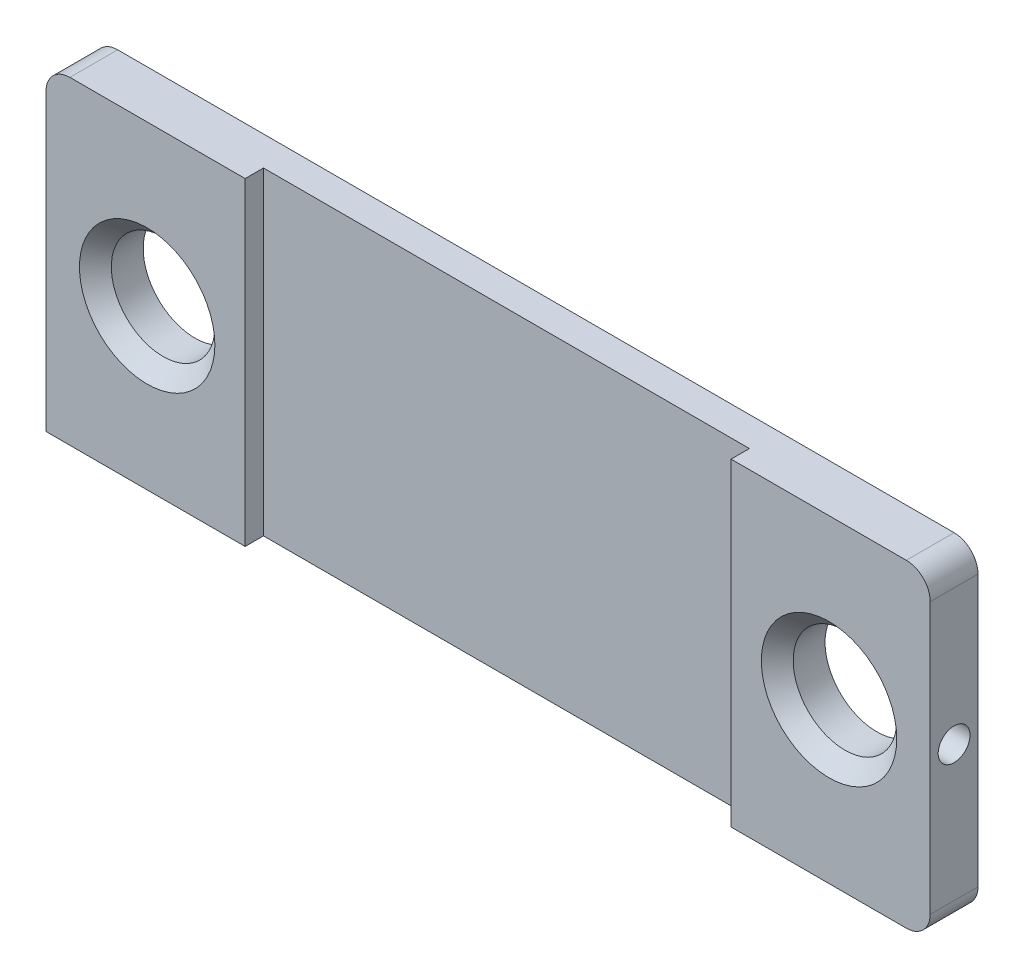
from build123d import *

# Parameters (mm, degrees)
ESQUISSE1_W               = 111
ESQUISSE1_H               = 40
ESQUISSE1_R               = 6.5
EXTRUSION1_DEPTH          = 3
CONG_1_R                  = 3
CHANFREIN1_SIZE           = 2
ESQUISSE2_W               = 61
ESQUISSE2_H               = 40
ENL_V_MAT_EXTRU_1_DEPTH   = 2.3
TROU_TARAUD_M3X0_51_D     = 2.5
TROU_TARAUD_M3X0_51_DEPTH = 7.5
TROU_TARAUD_M3X0_51_TIP   = 0.751075774


with BuildPart() as part:
    # Esquisse1 → Extrusion1 (new body, symmetric)
    with BuildSketch(Plane.XY):
        Rectangle(ESQUISSE1_W, ESQUISSE1_H)
        with Locations((-42.8, 0)):
            Circle(ESQUISSE1_R, mode=Mode.SUBTRACT)
        with Locations((42.8, 0)):
            Circle(ESQUISSE1_R, mode=Mode.SUBTRACT)
    extrude(amount=EXTRUSION1_DEPTH, both=True)

    # Congé1
    cong_1_edges = [part.edges().sort_by_distance(p)[0] for p in [
        (55.5, -20, 0),
        (-55.5, 20, 0),
        (55.5, 20, 0),
    ]]
    fillet(cong_1_edges, radius=CONG_1_R)

    # Chanfrein1
    chanfrein1_edges = [part.edges().sort_by_distance(p)[0] for p in [
        (-49.3, 0, 3),
        (36.3, 0, 3),
    ]]
    chamfer(chanfrein1_edges, length=CHANFREIN1_SIZE)

    # Esquisse2 → Enlèv. mat.-Extru.1 (cut)
    with BuildSketch(Plane.XY.offset(3)):
        Rectangle(ESQUISSE2_W, ESQUISSE2_H)
    extrude(amount=-ENL_V_MAT_EXTRU_1_DEPTH, mode=Mode.SUBTRACT)

    # Esquisse3 → Dégagement M1.61 (revolve, cut)
    with BuildSketch(Plane(origin=(-55.5, 0, 0), x_dir=(0, 0, 1), z_dir=(0, 1, 0))):
        Polygon((0, 0), (0, 5.7), (2, 3.7), (2, 0), align=None)
    d_gagement_m1_61 = revolve(axis=Axis((-61.85, 0, 0), (1, 0, 0)), mode=Mode.SUBTRACT)

    # Symétrie1: Dégagement M1.61 across plane
    add(d_gagement_m1_61.mirror(Plane(origin=(0, 0, 0), x_dir=(0, 0, 1), z_dir=(1, 0, 0))), mode=Mode.SUBTRACT)

    # Trou taraudé M3x0.51
    with Locations(Plane(origin=(-55.5, -17.9, 0), x_dir=(0, -1, 0), z_dir=(-1, 0, 0))):
        with Locations((0, 0)):
            Hole(TROU_TARAUD_M3X0_51_D / 2, depth=TROU_TARAUD_M3X0_51_DEPTH)
            with Locations((0, 0, -(TROU_TARAUD_M3X0_51_DEPTH + TROU_TARAUD_M3X0_51_TIP / 2))):  # 118° drill point
                Cone(0, TROU_TARAUD_M3X0_51_D / 2, TROU_TARAUD_M3X0_51_TIP, mode=Mode.SUBTRACT)


solid = part.part
